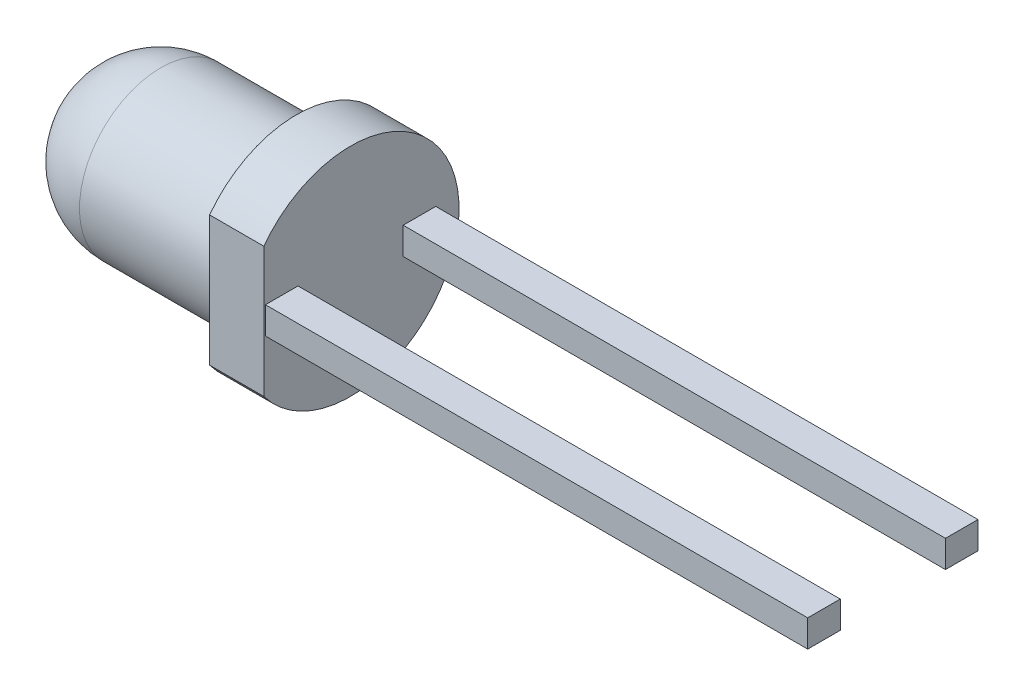
from build123d import *

# Parameters (mm, degrees)
SKETCH_2_W          = 0.6
SKETCH_2_H          = 0.5
EXTRUDE_1_DEPTH     = 10
EXTRUDE_1_2_DEPTH   = 10
SKETCH_3_W          = 0.8
SKETCH_3_H          = 2.4
CUT_EXTRUDE_1_DEPTH = 12


with BuildPart() as part:
    # Эскиз1 → Повернуть1 (revolve)
    with BuildSketch(Plane.XY):
        with BuildLine():
            Line((0, 0), (0, 2))
            Line((0, 2), (-1, 2))
            Line((-1, 2), (-1, 1.5))
            Line((-1, 1.5), (-3.5, 1.5))
            ThreePointArc((-3.5, 1.5), (-4.560660172, 1.060660172), (-5, 0))
            Line((-5, 0), (0, 0))
        make_face()
    revolve(axis=Axis((0, 0, 0), (-1, 0, 0)))

    # Эскиз3 → Вырез-Вытянуть1 (cut, through all)
    with BuildSketch(Plane.ZY.offset(1)):
        with Locations((2, 0)):
            Rectangle(SKETCH_3_W, SKETCH_3_H)
    extrude(amount=-CUT_EXTRUDE_1_DEPTH, mode=Mode.SUBTRACT)


with BuildPart() as body_2:
    # Эскиз2 → Бобышка-Вытянуть1 (new body)
    with BuildSketch(Plane(origin=(0, 0, 0), x_dir=(0, 0, -1), z_dir=(1, 0, 0))):
        with Locations((-1.27, 0)):
            Rectangle(SKETCH_2_W, SKETCH_2_H)
    extrude(amount=EXTRUDE_1_DEPTH)


with BuildPart() as body_3:
    # Эскиз2 → Extrude 1 2 (new body)
    with BuildSketch(Plane(origin=(0, 0, 0), x_dir=(0, 0, -1), z_dir=(1, 0, 0))):
        with Locations((1.27, 0)):
            Rectangle(SKETCH_2_W, SKETCH_2_H)
    extrude(amount=EXTRUDE_1_2_DEPTH)


solid = Compound([part.part, body_2.part, body_3.part])
